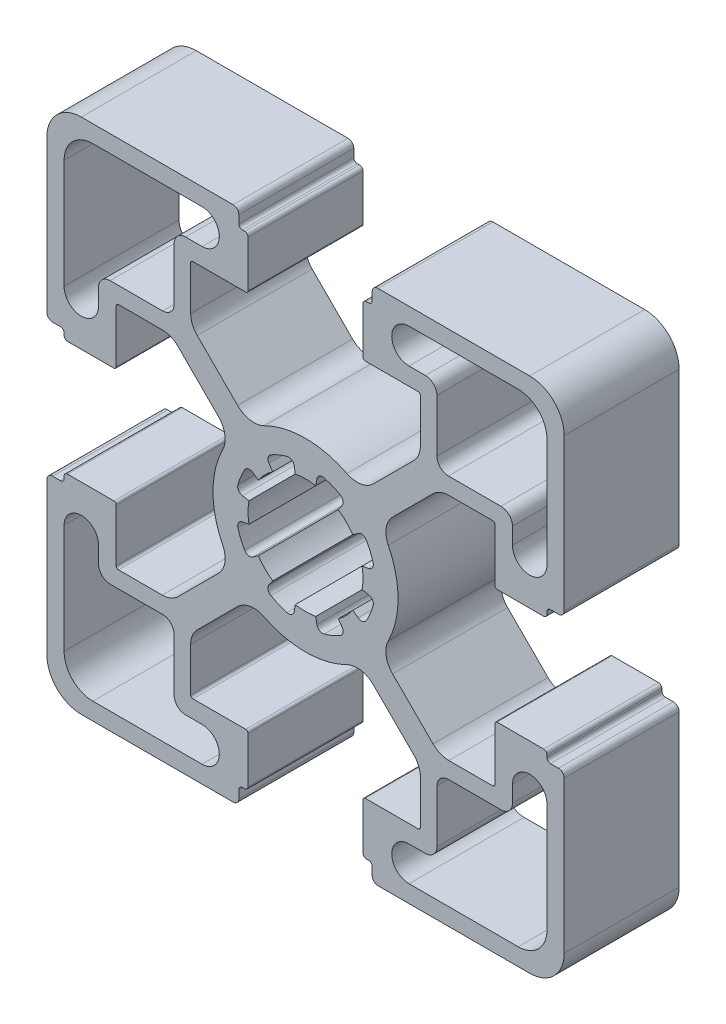
from build123d import *

# Parameters (mm, degrees)
BOSS_EXTRUDE1_DEPTH = 10


with BuildPart() as part:
    # Sketch1 → Boss-Extrude1 (new body)
    with BuildSketch(Plane.XY.offset(10)):
        with BuildLine():
            Line((-16.47, 5.2), (-16.47, 9.79))
            ThreePointArc((-16.47, 9.79), (-16.411421356, 9.931421356), (-16.27, 9.99))
            Line((-16.27, 9.99), (-12.46, 9.99))
            ThreePointArc((-12.46, 9.99), (-11.717594141, 9.842326293), (-11.088212844, 9.421787156))
            Line((-11.088212844, 9.421787156), (-7.574898431, 5.908472742))
            ThreePointArc((-7.574898431, 5.908472742), (-7.01494131, 4.81464974), (-7.200233985, 3.599879243))
            ThreePointArc((-7.200233985, 3.599879243), (-8.05, 0), (-7.200233985, -3.599879243))
            ThreePointArc((-7.200233985, -3.599879243), (-7.01494131, -4.81464974), (-7.574898431, -5.908472742))
            Line((-7.574898431, -5.908472742), (-11.088212844, -9.421787156))
            ThreePointArc((-11.088212844, -9.421787156), (-11.717594141, -9.842326293), (-12.46, -9.99))
            Line((-12.46, -9.99), (-16.27, -9.99))
            ThreePointArc((-16.27, -9.99), (-16.411421356, -9.931421356), (-16.47, -9.79))
            Line((-16.47, -9.79), (-16.47, -5.2))
            ThreePointArc((-16.47, -5.2), (-16.528578644, -5.058578644), (-16.67, -5))
            Line((-16.67, -5), (-20.7, -5))
            ThreePointArc((-20.7, -5), (-20.912132034, -5.087867966), (-21, -5.3))
            Line((-21, -5.3), (-21, -5.5))
            ThreePointArc((-21, -5.5), (-21.087867966, -5.712132034), (-21.3, -5.8))
            Line((-21.3, -5.8), (-22, -5.8))
            ThreePointArc((-22, -5.8), (-22.353553391, -5.946446609), (-22.5, -6.3))
            Line((-22.5, -6.3), (-22.5, -19.5))
            ThreePointArc((-22.5, -19.5), (-21.621320344, -21.621320344), (-19.5, -22.5))
            Line((-19.5, -22.5), (-6.3, -22.5))
            ThreePointArc((-6.3, -22.5), (-5.946446609, -22.353553391), (-5.8, -22))
            Line((-5.8, -22), (-5.8, -21.3))
            ThreePointArc((-5.8, -21.3), (-5.712132034, -21.087867966), (-5.5, -21))
            Line((-5.5, -21), (-5.3, -21))
            ThreePointArc((-5.3, -21), (-5.087867966, -20.912132034), (-5, -20.7))
            Line((-5, -20.7), (-5, -16.67))
            ThreePointArc((-5, -16.67), (-5.058578644, -16.528578644), (-5.2, -16.47))
            Line((-5.2, -16.47), (-9.79, -16.47))
            ThreePointArc((-9.79, -16.47), (-9.931421356, -16.411421356), (-9.99, -16.27))
            Line((-9.99, -16.27), (-9.99, -12.46))
            ThreePointArc((-9.99, -12.46), (-9.842326293, -11.717594141), (-9.421787156, -11.088212844))
            Line((-9.421787156, -11.088212844), (-5.908472742, -7.574898431))
            ThreePointArc((-5.908472742, -7.574898431), (-4.81464974, -7.01494131), (-3.599879243, -7.200233985))
            ThreePointArc((-3.599879243, -7.200233985), (0, -8.05), (3.599879243, -7.200233985))
            ThreePointArc((3.599879243, -7.200233985), (4.81464974, -7.01494131), (5.908472742, -7.574898431))
            Line((5.908472742, -7.574898431), (9.421787156, -11.088212844))
            ThreePointArc((9.421787156, -11.088212844), (9.842326293, -11.717594141), (9.99, -12.46))
            Line((9.99, -12.46), (9.99, -16.27))
            ThreePointArc((9.99, -16.27), (9.931421356, -16.411421356), (9.79, -16.47))
            Line((9.79, -16.47), (5.2, -16.47))
            ThreePointArc((5.2, -16.47), (5.058578644, -16.528578644), (5, -16.67))
            Line((5, -16.67), (5, -20.7))
            ThreePointArc((5, -20.7), (5.087867966, -20.912132034), (5.3, -21))
            Line((5.3, -21), (5.5, -21))
            ThreePointArc((5.5, -21), (5.712132034, -21.087867966), (5.8, -21.3))
            Line((5.8, -21.3), (5.8, -22))
            ThreePointArc((5.8, -22), (5.946446609, -22.353553391), (6.3, -22.5))
            Line((6.3, -22.5), (19.5, -22.5))
            ThreePointArc((19.5, -22.5), (21.621320344, -21.621320344), (22.5, -19.5))
            Line((22.5, -19.5), (22.5, -6.3))
            ThreePointArc((22.5, -6.3), (22.353553391, -5.946446609), (22, -5.8))
            Line((22, -5.8), (21.3, -5.8))
            ThreePointArc((21.3, -5.8), (21.087867966, -5.712132034), (21, -5.5))
            Line((21, -5.5), (21, -5.3))
            ThreePointArc((21, -5.3), (20.912132034, -5.087867966), (20.7, -5))
            Line((20.7, -5), (16.67, -5))
            ThreePointArc((16.67, -5), (16.528578644, -5.058578644), (16.47, -5.2))
            Line((16.47, -5.2), (16.47, -9.79))
            ThreePointArc((16.47, -9.79), (16.411421356, -9.931421356), (16.27, -9.99))
            Line((16.27, -9.99), (12.46, -9.99))
            ThreePointArc((12.46, -9.99), (11.717594141, -9.842326293), (11.088212844, -9.421787156))
            Line((11.088212844, -9.421787156), (7.574898431, -5.908472742))
            ThreePointArc((7.574898431, -5.908472742), (7.01494131, -4.81464974), (7.200233985, -3.599879243))
            ThreePointArc((7.200233985, -3.599879243), (8.05, 0), (7.200233985, 3.599879243))
            ThreePointArc((7.200233985, 3.599879243), (7.01494131, 4.81464974), (7.574898431, 5.908472742))
            Line((7.574898431, 5.908472742), (11.088212844, 9.421787156))
            ThreePointArc((11.088212844, 9.421787156), (11.717594141, 9.842326293), (12.46, 9.99))
            Line((12.46, 9.99), (16.27, 9.99))
            ThreePointArc((16.27, 9.99), (16.411421356, 9.931421356), (16.47, 9.79))
            Line((16.47, 9.79), (16.47, 5.2))
            ThreePointArc((16.47, 5.2), (16.528578644, 5.058578644), (16.67, 5))
            Line((16.67, 5), (20.7, 5))
            ThreePointArc((20.7, 5), (20.912132034, 5.087867966), (21, 5.3))
            Line((21, 5.3), (21, 5.5))
            ThreePointArc((21, 5.5), (21.087867966, 5.712132034), (21.3, 5.8))
            Line((21.3, 5.8), (22, 5.8))
            ThreePointArc((22, 5.8), (22.353553391, 5.946446609), (22.5, 6.3))
            Line((22.5, 6.3), (22.5, 19.5))
            ThreePointArc((22.5, 19.5), (21.621320344, 21.621320344), (19.5, 22.5))
            Line((19.5, 22.5), (6.3, 22.5))
            ThreePointArc((6.3, 22.5), (5.946446609, 22.353553391), (5.8, 22))
            Line((5.8, 22), (5.8, 21.3))
            ThreePointArc((5.8, 21.3), (5.712132034, 21.087867966), (5.5, 21))
            Line((5.5, 21), (5.3, 21))
            ThreePointArc((5.3, 21), (5.087867966, 20.912132034), (5, 20.7))
            Line((5, 20.7), (5, 16.67))
            ThreePointArc((5, 16.67), (5.058578644, 16.528578644), (5.2, 16.47))
            Line((5.2, 16.47), (9.79, 16.47))
            ThreePointArc((9.79, 16.47), (9.931421356, 16.411421356), (9.99, 16.27))
            Line((9.99, 16.27), (9.99, 12.46))
            ThreePointArc((9.99, 12.46), (9.842326293, 11.717594141), (9.421787156, 11.088212844))
            Line((9.421787156, 11.088212844), (5.908472742, 7.574898431))
            ThreePointArc((5.908472742, 7.574898431), (4.81464974, 7.01494131), (3.599879243, 7.200233985))
            ThreePointArc((3.599879243, 7.200233985), (0, 8.05), (-3.599879243, 7.200233985))
            ThreePointArc((-3.599879243, 7.200233985), (-4.81464974, 7.01494131), (-5.908472742, 7.574898431))
            Line((-5.908472742, 7.574898431), (-9.421787156, 11.088212844))
            ThreePointArc((-9.421787156, 11.088212844), (-9.842326293, 11.717594141), (-9.99, 12.46))
            Line((-9.99, 12.46), (-9.99, 16.27))
            ThreePointArc((-9.99, 16.27), (-9.931421356, 16.411421356), (-9.79, 16.47))
            Line((-9.79, 16.47), (-5.2, 16.47))
            ThreePointArc((-5.2, 16.47), (-5.058578644, 16.528578644), (-5, 16.67))
            Line((-5, 16.67), (-5, 20.7))
            ThreePointArc((-5, 20.7), (-5.087867966, 20.912132034), (-5.3, 21))
            Line((-5.3, 21), (-5.5, 21))
            ThreePointArc((-5.5, 21), (-5.712132034, 21.087867966), (-5.8, 21.3))
            Line((-5.8, 21.3), (-5.8, 22))
            ThreePointArc((-5.8, 22), (-5.946446609, 22.353553391), (-6.3, 22.5))
            Line((-6.3, 22.5), (-19.5, 22.5))
            ThreePointArc((-19.5, 22.5), (-21.621320344, 21.621320344), (-22.5, 19.5))
            Line((-22.5, 19.5), (-22.5, 6.3))
            ThreePointArc((-22.5, 6.3), (-22.353553391, 5.946446609), (-22, 5.8))
            Line((-22, 5.8), (-21.3, 5.8))
            ThreePointArc((-21.3, 5.8), (-21.087867966, 5.712132034), (-21, 5.5))
            Line((-21, 5.5), (-21, 5.3))
            ThreePointArc((-21, 5.3), (-20.912132034, 5.087867966), (-20.7, 5))
            Line((-20.7, 5), (-16.67, 5))
            ThreePointArc((-16.67, 5), (-16.528578644, 5.058578644), (-16.47, 5.2))
        make_face()
        with BuildLine():
            Line((-4.920152437, 0.89), (-5.485877984, 0.98771777))
            ThreePointArc((-5.485877984, 0.98771777), (-5.822771092, 1.21224676), (-5.882985131, 1.61260223))
            ThreePointArc((-5.882985131, 1.61260223), (-5.635665148, 2.334368937), (-5.300180652, 3.019616708))
            ThreePointArc((-5.300180652, 3.019616708), (-4.974508828, 3.26013302), (-4.577523456, 3.180679591))
            Line((-4.577523456, 3.180679591), (-4.108398188, 2.849748117))
            ThreePointArc((-4.108398188, 2.849748117), (-3.535533906, 3.535533906), (-2.849748117, 4.108398188))
            Line((-2.849748117, 4.108398188), (-3.180679591, 4.577523456))
            ThreePointArc((-3.180679591, 4.577523456), (-3.26013302, 4.974508828), (-3.019616708, 5.300180652))
            ThreePointArc((-3.019616708, 5.300180652), (-2.334368937, 5.635665148), (-1.61260223, 5.882985131))
            ThreePointArc((-1.61260223, 5.882985131), (-1.21224676, 5.822771092), (-0.98771777, 5.485877984))
            Line((-0.98771777, 5.485877984), (-0.89, 4.920152437))
            ThreePointArc((-0.89, 4.920152437), (0, 5), (0.89, 4.920152437))
            Line((0.89, 4.920152437), (0.98771777, 5.485877984))
            ThreePointArc((0.98771777, 5.485877984), (1.21224676, 5.822771092), (1.61260223, 5.882985131))
            ThreePointArc((1.61260223, 5.882985131), (2.334368937, 5.635665148), (3.019616708, 5.300180652))
            ThreePointArc((3.019616708, 5.300180652), (3.26013302, 4.974508828), (3.180679591, 4.577523456))
            Line((3.180679591, 4.577523456), (2.849748117, 4.108398188))
            ThreePointArc((2.849748117, 4.108398188), (3.535533906, 3.535533906), (4.108398188, 2.849748117))
            Line((4.108398188, 2.849748117), (4.577523456, 3.180679591))
            ThreePointArc((4.577523456, 3.180679591), (4.974508828, 3.26013302), (5.300180652, 3.019616708))
            ThreePointArc((5.300180652, 3.019616708), (5.635665148, 2.334368937), (5.882985131, 1.61260223))
            ThreePointArc((5.882985131, 1.61260223), (5.822771092, 1.21224676), (5.485877984, 0.98771777))
            Line((5.485877984, 0.98771777), (4.920152437, 0.89))
            ThreePointArc((4.920152437, 0.89), (5, 0), (4.920152437, -0.89))
            Line((4.920152437, -0.89), (5.485877984, -0.98771777))
            ThreePointArc((5.485877984, -0.98771777), (5.822771092, -1.21224676), (5.882985131, -1.61260223))
            ThreePointArc((5.882985131, -1.61260223), (5.635665148, -2.334368937), (5.300180652, -3.019616708))
            ThreePointArc((5.300180652, -3.019616708), (4.974508828, -3.26013302), (4.577523456, -3.180679591))
            Line((4.577523456, -3.180679591), (4.108398188, -2.849748117))
            ThreePointArc((4.108398188, -2.849748117), (3.535533906, -3.535533906), (2.849748117, -4.108398188))
            Line((2.849748117, -4.108398188), (3.180679591, -4.577523456))
            ThreePointArc((3.180679591, -4.577523456), (3.26013302, -4.974508828), (3.019616708, -5.300180652))
            ThreePointArc((3.019616708, -5.300180652), (2.334368937, -5.635665148), (1.61260223, -5.882985131))
            ThreePointArc((1.61260223, -5.882985131), (1.21224676, -5.822771092), (0.98771777, -5.485877984))
            Line((0.98771777, -5.485877984), (0.89, -4.920152437))
            ThreePointArc((0.89, -4.920152437), (0, -5), (-0.89, -4.920152437))
            Line((-0.89, -4.920152437), (-0.98771777, -5.485877984))
            ThreePointArc((-0.98771777, -5.485877984), (-1.21224676, -5.822771092), (-1.61260223, -5.882985131))
            ThreePointArc((-1.61260223, -5.882985131), (-2.334368937, -5.635665148), (-3.019616708, -5.300180652))
            ThreePointArc((-3.019616708, -5.300180652), (-3.26013302, -4.974508828), (-3.180679591, -4.577523456))
            Line((-3.180679591, -4.577523456), (-2.849748117, -4.108398188))
            ThreePointArc((-2.849748117, -4.108398188), (-3.535533906, -3.535533906), (-4.108398188, -2.849748117))
            Line((-4.108398188, -2.849748117), (-4.577523456, -3.180679591))
            ThreePointArc((-4.577523456, -3.180679591), (-4.974508828, -3.26013302), (-5.300180652, -3.019616708))
            ThreePointArc((-5.300180652, -3.019616708), (-5.635665148, -2.334368937), (-5.882985131, -1.61260223))
            ThreePointArc((-5.882985131, -1.61260223), (-5.822771092, -1.21224676), (-5.485877984, -0.98771777))
            Line((-5.485877984, -0.98771777), (-4.920152437, -0.89))
            ThreePointArc((-4.920152437, -0.89), (-5, 0), (-4.920152437, 0.89))
        make_face(mode=Mode.SUBTRACT)
        with BuildLine():
            Line((-21, 9), (-21, 18.5))
            ThreePointArc((-21, 18.5), (-20.267766953, 20.267766953), (-18.5, 21))
            Line((-18.5, 21), (-9, 21))
            ThreePointArc((-9, 21), (-7.5, 19.5), (-9, 18))
            Line((-9, 18), (-10.43, 18))
            ThreePointArc((-10.43, 18), (-11.137106781, 17.707106781), (-11.43, 17))
            Line((-11.43, 17), (-11.43, 12.43))
            ThreePointArc((-11.43, 12.43), (-11.722893219, 11.722893219), (-12.43, 11.43))
            Line((-12.43, 11.43), (-17, 11.43))
            ThreePointArc((-17, 11.43), (-17.707106781, 11.137106781), (-18, 10.43))
            Line((-18, 10.43), (-18, 9))
            ThreePointArc((-18, 9), (-19.5, 7.5), (-21, 9))
        make_face(mode=Mode.SUBTRACT)
        with BuildLine():
            Line((17, 11.43), (12.43, 11.43))
            ThreePointArc((12.43, 11.43), (11.722893219, 11.722893219), (11.43, 12.43))
            Line((11.43, 12.43), (11.43, 17))
            ThreePointArc((11.43, 17), (11.137106781, 17.707106781), (10.43, 18))
            Line((10.43, 18), (9, 18))
            ThreePointArc((9, 18), (7.5, 19.5), (9, 21))
            Line((9, 21), (18.5, 21))
            ThreePointArc((18.5, 21), (20.267766953, 20.267766953), (21, 18.5))
            Line((21, 18.5), (21, 9))
            ThreePointArc((21, 9), (19.5, 7.5), (18, 9))
            Line((18, 9), (18, 10.43))
            ThreePointArc((18, 10.43), (17.707106781, 11.137106781), (17, 11.43))
        make_face(mode=Mode.SUBTRACT)
        with BuildLine():
            Line((-10.43, -18), (-9, -18))
            ThreePointArc((-9, -18), (-7.5, -19.5), (-9, -21))
            Line((-9, -21), (-18.5, -21))
            ThreePointArc((-18.5, -21), (-20.267766953, -20.267766953), (-21, -18.5))
            Line((-21, -18.5), (-21, -9))
            ThreePointArc((-21, -9), (-19.5, -7.5), (-18, -9))
            Line((-18, -9), (-18, -10.43))
            ThreePointArc((-18, -10.43), (-17.707106781, -11.137106781), (-17, -11.43))
            Line((-17, -11.43), (-12.43, -11.43))
            ThreePointArc((-12.43, -11.43), (-11.722893219, -11.722893219), (-11.43, -12.43))
            Line((-11.43, -12.43), (-11.43, -17))
            ThreePointArc((-11.43, -17), (-11.137106781, -17.707106781), (-10.43, -18))
        make_face(mode=Mode.SUBTRACT)
        with BuildLine():
            Line((9, -18), (10.43, -18))
            ThreePointArc((10.43, -18), (11.137106781, -17.707106781), (11.43, -17))
            Line((11.43, -17), (11.43, -12.43))
            ThreePointArc((11.43, -12.43), (11.722893219, -11.722893219), (12.43, -11.43))
            Line((12.43, -11.43), (17, -11.43))
            ThreePointArc((17, -11.43), (17.707106781, -11.137106781), (18, -10.43))
            Line((18, -10.43), (18, -9))
            ThreePointArc((18, -9), (19.5, -7.5), (21, -9))
            Line((21, -9), (21, -18.5))
            ThreePointArc((21, -18.5), (20.267766953, -20.267766953), (18.5, -21))
            Line((18.5, -21), (9, -21))
            ThreePointArc((9, -21), (7.5, -19.5), (9, -18))
        make_face(mode=Mode.SUBTRACT)
    extrude(amount=-BOSS_EXTRUDE1_DEPTH)


solid = part.part
